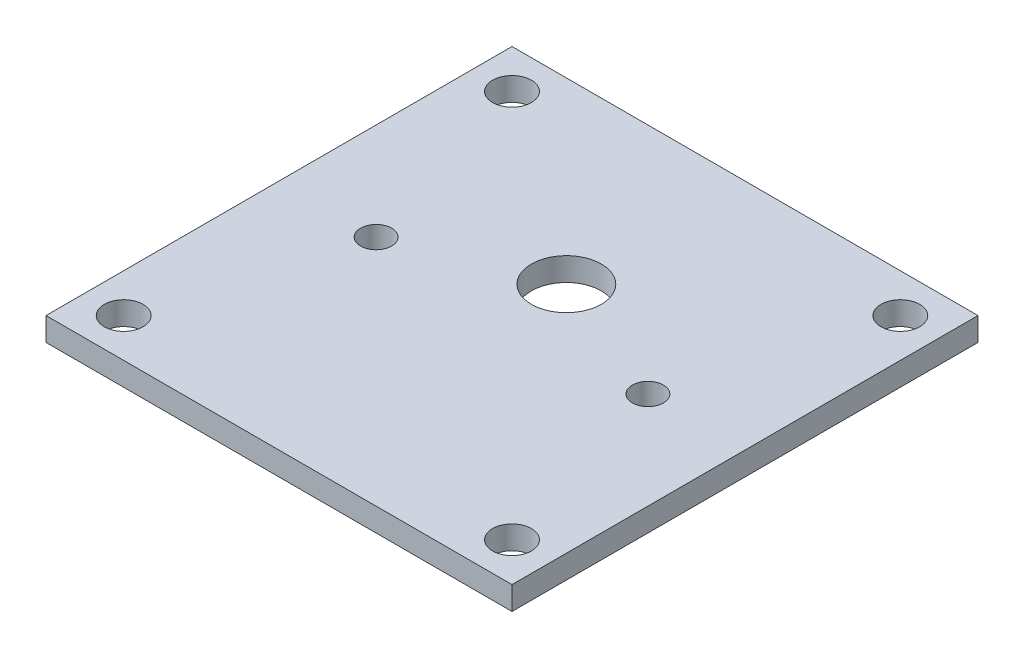
from build123d import *

# Parameters (mm, degrees)
SKETCH1_W           = 60
SKETCH1_H           = 60
SKETCH1_R           = 2.5
SKETCH1_R_2         = 4.5
SKETCH1_R_3         = 2
BOSS_EXTRUDE1_DEPTH = 3


with BuildPart() as part:
    # Sketch1 → Boss-Extrude1 (new body)
    with BuildSketch(Plane(origin=(0, 0, 0), x_dir=(1, 0, 0), z_dir=(0, 1, 0))):
        Rectangle(SKETCH1_W, SKETCH1_H)
        with Locations((-25, -25)):
            Circle(SKETCH1_R, mode=Mode.SUBTRACT)
        with Locations((25, -25)):
            Circle(SKETCH1_R, mode=Mode.SUBTRACT)
        with BuildLine():
            Line((-13.555441712, -3.5), (-17.495441712, -3.5))
            ThreePointArc((-17.495441712, -3.5), (-20.995441712, 0), (-17.495441712, 3.5))
            Line((-17.495441712, 3.5), (-13.555441712, 3.5))
            ThreePointArc((-13.555441712, 3.5), (0, 14), (13.555441712, 3.5))
            Line((13.555441712, 3.5), (17.495441712, 3.5))
            ThreePointArc((17.495441712, 3.5), (20.995441712, 0), (17.495441712, -3.5))
            Line((17.495441712, -3.5), (13.555441712, -3.5))
            ThreePointArc((13.555441712, -3.5), (0, -14), (-13.555441712, -3.5))
        make_face(mode=Mode.SUBTRACT)
        with Locations((-25, 25)):
            Circle(SKETCH1_R, mode=Mode.SUBTRACT)
        with Locations((25, 25)):
            Circle(SKETCH1_R, mode=Mode.SUBTRACT)
        with BuildLine():
            ThreePointArc((-13.999088699, -0.159736057), (-13.878125858, -1.843264133), (-13.555441712, -3.5))
            ThreePointArc((-13.555441712, -3.5), (0, -14), (13.555441712, -3.5))
            ThreePointArc((13.555441712, -3.5), (13.878125858, -1.843264133), (13.999088699, -0.159736057))
            ThreePointArc((13.999088699, -0.159736057), (13.995441712, 0), (13.999088699, 0.159736057))
            ThreePointArc((13.999088699, 0.159736057), (13.878125858, 1.843264133), (13.555441712, 3.5))
            ThreePointArc((13.555441712, 3.5), (0, 14), (-13.555441712, 3.5))
            ThreePointArc((-13.555441712, 3.5), (-13.878125858, 1.843264133), (-13.999088699, 0.159736057))
            ThreePointArc((-13.999088699, 0.159736057), (-13.995441712, 0), (-13.999088699, -0.159736057))
        make_face()
        with Locations((0, 7)):
            Circle(SKETCH1_R_2, mode=Mode.SUBTRACT)
        with BuildLine():
            ThreePointArc((-17.495441712, 3.5), (-20.995441712, 0), (-17.495441712, -3.5))
            Line((-17.495441712, -3.5), (-13.555441712, -3.5))
            ThreePointArc((-13.555441712, -3.5), (-13.878125858, -1.843264133), (-13.999088699, -0.159736057))
            ThreePointArc((-13.999088699, -0.159736057), (-14, 0), (-13.999088699, 0.159736057))
            ThreePointArc((-13.999088699, 0.159736057), (-13.878125858, 1.843264133), (-13.555441712, 3.5))
            Line((-13.555441712, 3.5), (-17.495441712, 3.5))
        make_face()
        with Locations((-17.495441712, 0)):
            Circle(SKETCH1_R_3, mode=Mode.SUBTRACT)
        with BuildLine():
            ThreePointArc((13.999088699, -0.159736057), (13.878125858, -1.843264133), (13.555441712, -3.5))
            Line((13.555441712, -3.5), (17.495441712, -3.5))
            ThreePointArc((17.495441712, -3.5), (20.995441712, 0), (17.495441712, 3.5))
            Line((17.495441712, 3.5), (13.555441712, 3.5))
            ThreePointArc((13.555441712, 3.5), (13.878125858, 1.843264133), (13.999088699, 0.159736057))
            ThreePointArc((13.999088699, 0.159736057), (13.999772173, 0.079869328), (14, 0))
            ThreePointArc((14, 0), (13.999772173, -0.079869328), (13.999088699, -0.159736057))
        make_face()
        with Locations((17.495441712, 0)):
            Circle(SKETCH1_R_3, mode=Mode.SUBTRACT)
    extrude(amount=BOSS_EXTRUDE1_DEPTH)


solid = part.part
